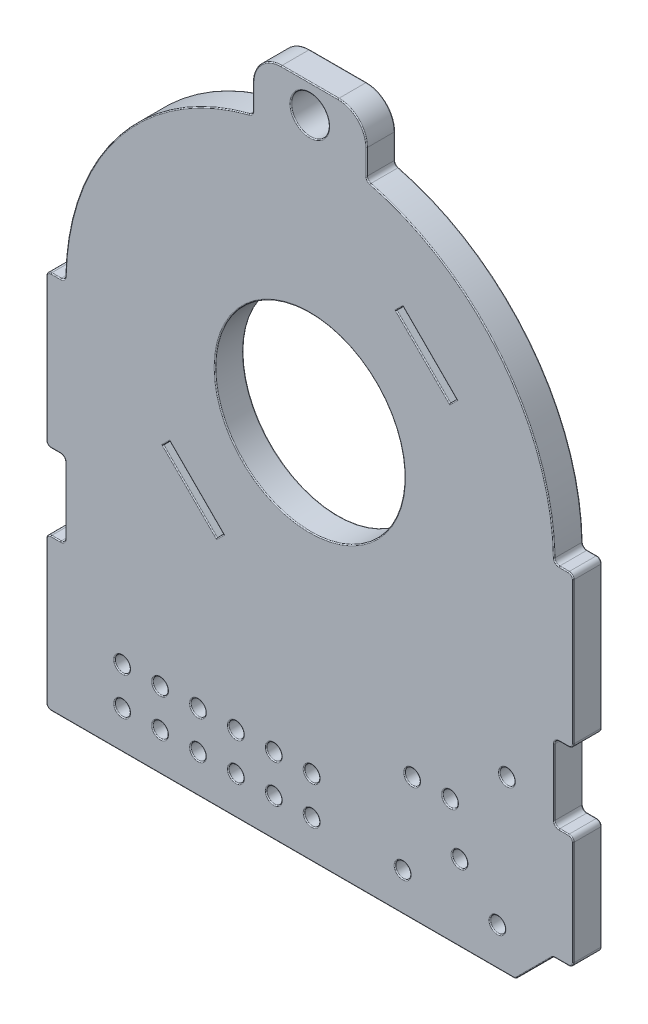
from build123d import *

# Parameters (mm, degrees)
SKETCH1_R           = 0.4
SKETCH1_R_2         = 1
BOSS_EXTRUDE1_DEPTH = 1.5
SKETCH2_R           = 5
CUT_EXTRUDE1_DEPTH  = 2.5
FILLET1_R           = 0.05


with BuildPart() as part:
    # Sketch1 → Boss-Extrude1 (new body)
    with BuildSketch(Plane.XY):
        with BuildLine():
            Line((13.147623359, 0), (13.65, 0))
            ThreePointArc((13.65, 0), (13.826776695, -0.073223305), (13.9, -0.25))
            Line((13.9, -0.25), (13.9, -7.75))
            ThreePointArc((13.9, -7.75), (13.826776695, -7.926776695), (13.65, -8))
            Line((13.65, -8), (13.15, -8))
            ThreePointArc((13.15, -8), (12.973223305, -8.073223305), (12.9, -8.25))
            Line((12.9, -8.25), (12.9, -11.75))
            ThreePointArc((12.9, -11.75), (12.973223305, -11.926776695), (13.15, -12))
            Line((13.15, -12), (13.65, -12))
            ThreePointArc((13.65, -12), (13.826776695, -12.073223305), (13.9, -12.25))
            Line((13.9, -12.25), (13.9, -17.75))
            ThreePointArc((13.9, -17.75), (13.826776695, -17.926776695), (13.65, -18))
            Line((13.65, -18), (12.948952708, -18))
            ThreePointArc((12.948952708, -18), (12.85328185, -18.019030117), (12.772176013, -18.073223305))
            Line((12.772176013, -18.073223305), (10.918622622, -19.926776695))
            ThreePointArc((10.918622622, -19.926776695), (10.837516785, -19.980969883), (10.741845927, -20))
            Line((10.741845927, -20), (-13.65, -20))
            ThreePointArc((-13.65, -20), (-13.826776695, -19.926776695), (-13.9, -19.75))
            Line((-13.9, -19.75), (-13.9, -12.25))
            ThreePointArc((-13.9, -12.25), (-13.826776695, -12.073223305), (-13.65, -12))
            Line((-13.65, -12), (-13.15, -12))
            ThreePointArc((-13.15, -12), (-12.973223305, -11.926776695), (-12.9, -11.75))
            Line((-12.9, -11.75), (-12.9, -8.25))
            ThreePointArc((-12.9, -8.25), (-12.973223305, -8.073223305), (-13.15, -8))
            Line((-13.15, -8), (-13.65, -8))
            ThreePointArc((-13.65, -8), (-13.826776695, -7.926776695), (-13.9, -7.75))
            Line((-13.9, -7.75), (-13.9, -0.25))
            ThreePointArc((-13.9, -0.25), (-13.826776695, -0.073223305), (-13.65, 0))
            Line((-13.65, 0), (-13.147623359, 0))
            ThreePointArc((-13.147623359, 0), (-12.972535114, 0.071550829), (-12.897668543, 0.245247148))
            ThreePointArc((-12.897668543, 0.245247148), (-10.111008119, 8.011086994), (-3.188212928, 12.499811932))
            ThreePointArc((-3.188212928, 12.499811932), (-3.052583223, 12.588672465), (-3, 12.742056349))
            Line((-3, 12.742056349), (-3, 14.0463142))
            ThreePointArc((-3, 14.0463142), (-2.560660172, 15.106974372), (-1.5, 15.5463142))
            Line((-1.5, 15.5463142), (1.5, 15.5463142))
            ThreePointArc((1.5, 15.5463142), (2.560660172, 15.106974372), (3, 14.0463142))
            Line((3, 14.0463142), (3, 12.742056349))
            ThreePointArc((3, 12.742056349), (3.052583223, 12.588672465), (3.188212928, 12.499811932))
            ThreePointArc((3.188212928, 12.499811932), (10.111008119, 8.011086994), (12.897668543, 0.245247148))
            ThreePointArc((12.897668543, 0.245247148), (12.972535114, 0.071550829), (13.147623359, 0))
        make_face()
        with Locations((10.4, -11)):
            Circle(SKETCH1_R, mode=Mode.SUBTRACT)
        with Locations((7.9, -16)):
            Circle(SKETCH1_R, mode=Mode.SUBTRACT)
        with Locations((9.9, -18)):
            Circle(SKETCH1_R, mode=Mode.SUBTRACT)
        with Locations((4.9, -18)):
            Circle(SKETCH1_R, mode=Mode.SUBTRACT)
        with Locations((7.4, -13.5)):
            Circle(SKETCH1_R, mode=Mode.SUBTRACT)
        with Locations((5.4, -13.5)):
            Circle(SKETCH1_R, mode=Mode.SUBTRACT)
        with Locations((0, 14.0463142)):
            Circle(SKETCH1_R_2, mode=Mode.SUBTRACT)
        with Locations((0.1, -18)):
            Circle(SKETCH1_R, mode=Mode.SUBTRACT)
        with Locations((-1.9, -18)):
            Circle(SKETCH1_R, mode=Mode.SUBTRACT)
        with Locations((-3.9, -18)):
            Circle(SKETCH1_R, mode=Mode.SUBTRACT)
        with Locations((-5.9, -18)):
            Circle(SKETCH1_R, mode=Mode.SUBTRACT)
        with Locations((-7.9, -18)):
            Circle(SKETCH1_R, mode=Mode.SUBTRACT)
        with Locations((-9.9, -18)):
            Circle(SKETCH1_R, mode=Mode.SUBTRACT)
        with Locations((-1.9, -16)):
            Circle(SKETCH1_R, mode=Mode.SUBTRACT)
        with Locations((-3.9, -16)):
            Circle(SKETCH1_R, mode=Mode.SUBTRACT)
        with Locations((-5.9, -16)):
            Circle(SKETCH1_R, mode=Mode.SUBTRACT)
        with Locations((-7.9, -16)):
            Circle(SKETCH1_R, mode=Mode.SUBTRACT)
        with Locations((-9.9, -16)):
            Circle(SKETCH1_R, mode=Mode.SUBTRACT)
        with Locations((0.1, -16)):
            Circle(SKETCH1_R, mode=Mode.SUBTRACT)
    extrude(amount=BOSS_EXTRUDE1_DEPTH)

    # Sketch2 → Cut-Extrude1 (cut, through all)
    with BuildSketch(Plane.XY.offset(1.5)):
        Circle(SKETCH2_R)
        Polygon((4.560838739, 7.389265863), (4.914392129, 7.742819254), (7.742819254, 4.914392129), (7.389265863, 4.560838739), align=None)
        Polygon((-7.742819254, -4.914392129), (-4.914392129, -7.742819254), (-4.560838739, -7.389265863), (-7.389265863, -4.560838739), align=None)
    extrude(amount=-CUT_EXTRUDE1_DEPTH, mode=Mode.SUBTRACT)

    # Fillet1
    fillet1_edges = [part.edges().sort_by_distance(p)[0] for p in [
        (10.837516785, -19.980969883, 1.5),
        (-13.826776695, -7.926776695, 1.5),
        (4.5, -18, 1.5),
        (-13.4, -8, 1.5),
        (-12.973223305, -8.073223305, 1.5),
        (7, -13.5, 1.5),
        (-12.9, -10, 1.5),
        (5, -13.5, 1.5),
        (-12.973223305, -11.926776695, 1.5),
        (-1, 14.0463142, 1.5),
        (-13.4, -12, 1.5),
        (-13.826776695, -12.073223305, 1.5),
        (-0.3, -18, 1.5),
        (-13.9, -16, 1.5),
        (-2.3, -18, 1.5),
        (-4.3, -18, 1.5),
        (-6.3, -18, 1.5),
        (11.845399317, -19, 1.5),
        (-8.3, -18, 1.5),
        (-10.3, -18, 1.5),
        (-2.3, -16, 1.5),
        (-4.3, -16, 1.5),
        (-6.3, -16, 1.5),
        (-8.3, -16, 1.5),
        (-10.3, -16, 1.5),
        (-0.3, -16, 1.5),
        (12.85328185, -18.019030117, 1.5),
        (-5, 0, 0),
        (-5, 0, 1.5),
        (13.299476354, -18, 1.5),
        (5.975052301, 5.975052301, 1.5),
        (7.566042559, 4.737615434, 1.5),
        (6.328605692, 6.328605692, 1.5),
        (4.737615434, 7.566042559, 1.5),
        (-7.566042559, -4.737615434, 1.5),
        (-6.328605692, -6.328605692, 1.5),
        (-4.737615434, -7.566042559, 1.5),
        (-5.975052301, -5.975052301, 1.5),
        (13.826776695, -17.926776695, 1.5),
        (13.9, -15, 1.5),
        (13.826776695, -12.073223305, 1.5),
        (13.4, -12, 1.5),
        (-13.9, -16, 0),
        (-13.826776695, -12.073223305, 0),
        (12.973223305, -11.926776695, 1.5),
        (-13.4, -12, 0),
        (-12.973223305, -11.926776695, 0),
        (-12.9, -10, 0),
        (-12.973223305, -8.073223305, 0),
        (-13.4, -8, 0),
        (-13.826776695, -7.926776695, 0),
        (-13.9, -4, 0),
        (-13.826776695, -0.073223305, 0),
        (12.9, -10, 1.5),
        (-13.39881168, 0, 0),
        (-12.972535114, 0.071550829, 0),
        (-10.111008119, 8.011086994, 0),
        (-3.052583223, 12.588672465, 0),
        (-3, 13.394185274, 0),
        (-2.560660172, 15.106974372, 0),
        (0, 15.5463142, 0),
        (-13.826776695, -19.926776695, 1.5),
        (12.973223305, -8.073223305, 1.5),
        (2.560660172, 15.106974372, 0),
        (3, 13.394185274, 0),
        (3.052583223, 12.588672465, 0),
        (10.111008119, 8.011086994, 0),
        (12.972535114, 0.071550829, 0),
        (13.39881168, 0, 0),
        (13.826776695, -0.073223305, 0),
        (13.9, -4, 0),
        (13.4, -8, 1.5),
        (13.826776695, -7.926776695, 0),
        (13.4, -8, 0),
        (12.973223305, -8.073223305, 0),
        (12.9, -10, 0),
        (12.973223305, -11.926776695, 0),
        (13.4, -12, 0),
        (13.826776695, -12.073223305, 0),
        (13.826776695, -7.926776695, 1.5),
        (13.9, -15, 0),
        (13.826776695, -17.926776695, 0),
        (13.299476354, -18, 0),
        (12.85328185, -18.019030117, 0),
        (11.845399317, -19, 0),
        (10.837516785, -19.980969883, 0),
        (-1.454077037, -20, 0),
        (-13.826776695, -19.926776695, 0),
        (13.9, -4, 1.5),
        (13.826776695, -0.073223305, 1.5),
        (13.39881168, 0, 1.5),
        (12.972535114, 0.071550829, 1.5),
        (10.111008119, 8.011086994, 1.5),
        (3.052583223, 12.588672465, 1.5),
        (3, 13.394185274, 1.5),
        (-1.454077037, -20, 1.5),
        (2.560660172, 15.106974372, 1.5),
        (0, 15.5463142, 1.5),
        (-2.560660172, 15.106974372, 1.5),
        (-3, 13.394185274, 1.5),
        (-3.052583223, 12.588672465, 1.5),
        (-10.111008119, 8.011086994, 1.5),
        (-12.972535114, 0.071550829, 1.5),
        (-13.39881168, 0, 1.5),
        (10, -11, 1.5),
        (-13.826776695, -0.073223305, 1.5),
        (7.5, -16, 1.5),
        (-13.9, -4, 1.5),
        (9.5, -18, 1.5),
    ]]
    fillet(fillet1_edges, radius=FILLET1_R)


solid = part.part
